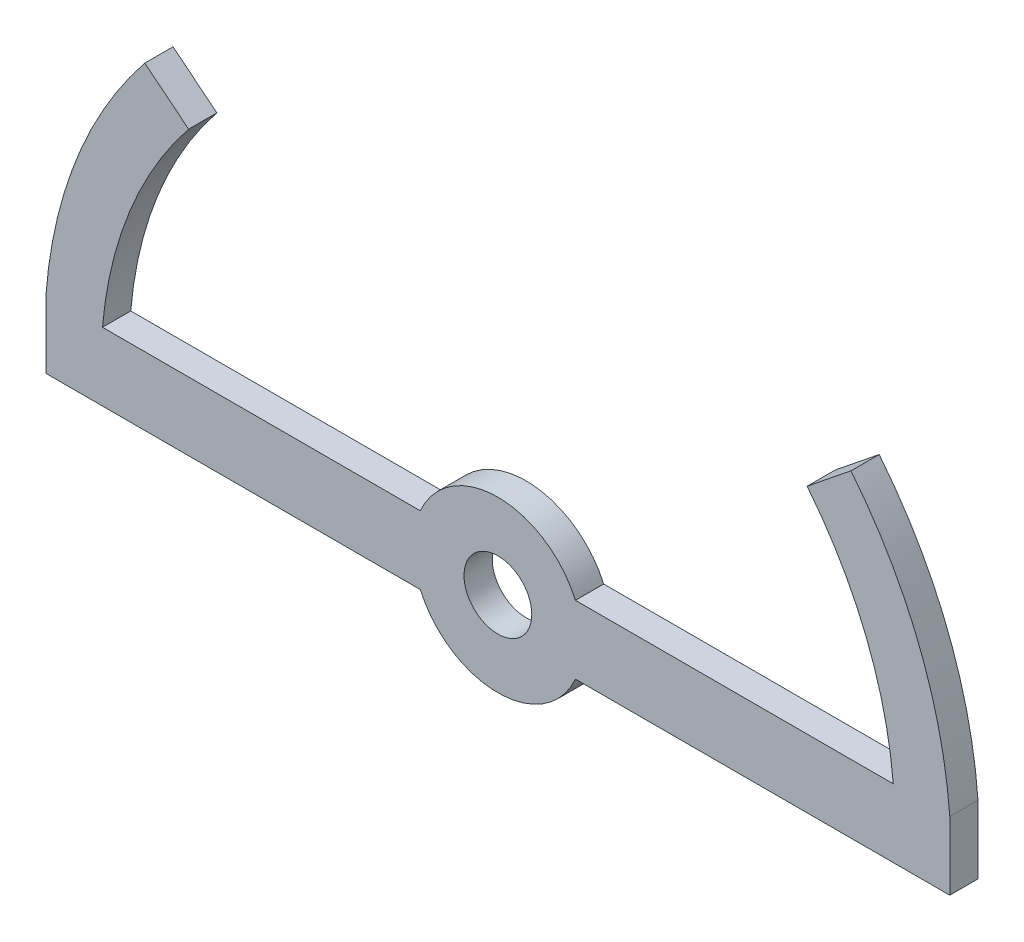
from build123d import *

# Parameters (mm, degrees)
SKETCH1_R           = 7.5
SKETCH1_R_2         = 3
BOSS_EXTRUDE1_DEPTH = 2.5
SKETCH2_W           = 80
SKETCH2_H           = 6.039840068
SKETCH2_R           = 3
BOSS_EXTRUDE2_DEPTH = 2.5
BOSS_EXTRUDE3_DEPTH = 2.5


with BuildPart() as part:
    # Sketch1 → Boss-Extrude1 (new body)
    with BuildSketch(Plane.XY):
        Circle(SKETCH1_R)
        Circle(SKETCH1_R_2, mode=Mode.SUBTRACT)
    extrude(amount=-BOSS_EXTRUDE1_DEPTH)

    # Sketch2 → Boss-Extrude2 (add)
    with BuildSketch(Plane(origin=(0, 0, -2.5), x_dir=(-1, 0, 0), z_dir=(0, 0, -1))):
        Rectangle(SKETCH2_W, SKETCH2_H)
        Circle(SKETCH2_R, mode=Mode.SUBTRACT)
    extrude(amount=-BOSS_EXTRUDE2_DEPTH)

    # Sketch4 → Boss-Extrude3 (add)
    with BuildSketch(Plane(origin=(0, 0, -2.5), x_dir=(-1, 0, 0), z_dir=(0, 0, -1))):
        with BuildLine():
            Line((27.372304228, 22.019920034), (31.255531094, 25.143820176))
            ThreePointArc((31.255531094, 25.143820176), (37.305554777, 14.745016099), (40, 3.019920034))
            Line((40, 3.019920034), (35, 3.019920034))
            ThreePointArc((35, 3.019920034), (32.601013537, 13.087927007), (27.372304228, 22.019920034))
        make_face()
        with BuildLine():
            Line((-27.372304228, 22.019920034), (-31.255531094, 25.143820176))
            ThreePointArc((-31.255531094, 25.143820176), (-37.305554777, 14.745016099), (-40, 3.019920034))
            Line((-40, 3.019920034), (-35, 3.019920034))
            ThreePointArc((-35, 3.019920034), (-32.601013537, 13.087927007), (-27.372304228, 22.019920034))
        make_face()
    extrude(amount=-BOSS_EXTRUDE3_DEPTH)


solid = part.part
